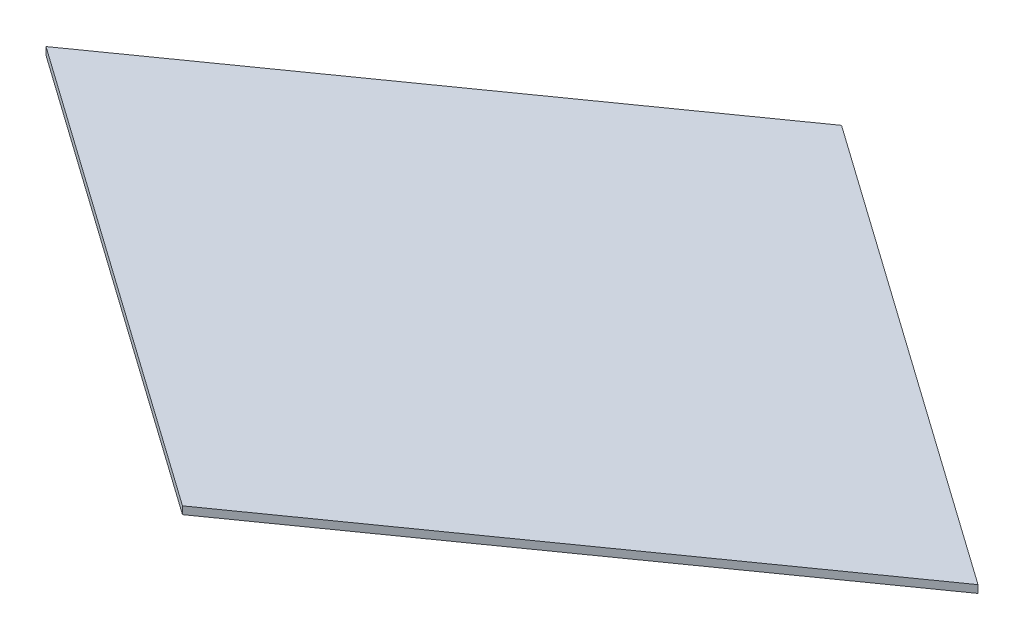
from build123d import *

# Parameters (mm, degrees)
BOSS_EXTRUDE1_DEPTH = 1.25


with BuildPart() as part:
    # Sketch1 → Boss-Extrude1 (new body, symmetric)
    with BuildSketch(Plane(origin=(0, 0, 0), x_dir=(1, 0, 0), z_dir=(0, 1, 0))):
        Polygon((-152.4, 0), (0, 107.763073453), (152.4, 0), (0, -107.763073453), align=None)
    extrude(amount=BOSS_EXTRUDE1_DEPTH, both=True)


solid = part.part
